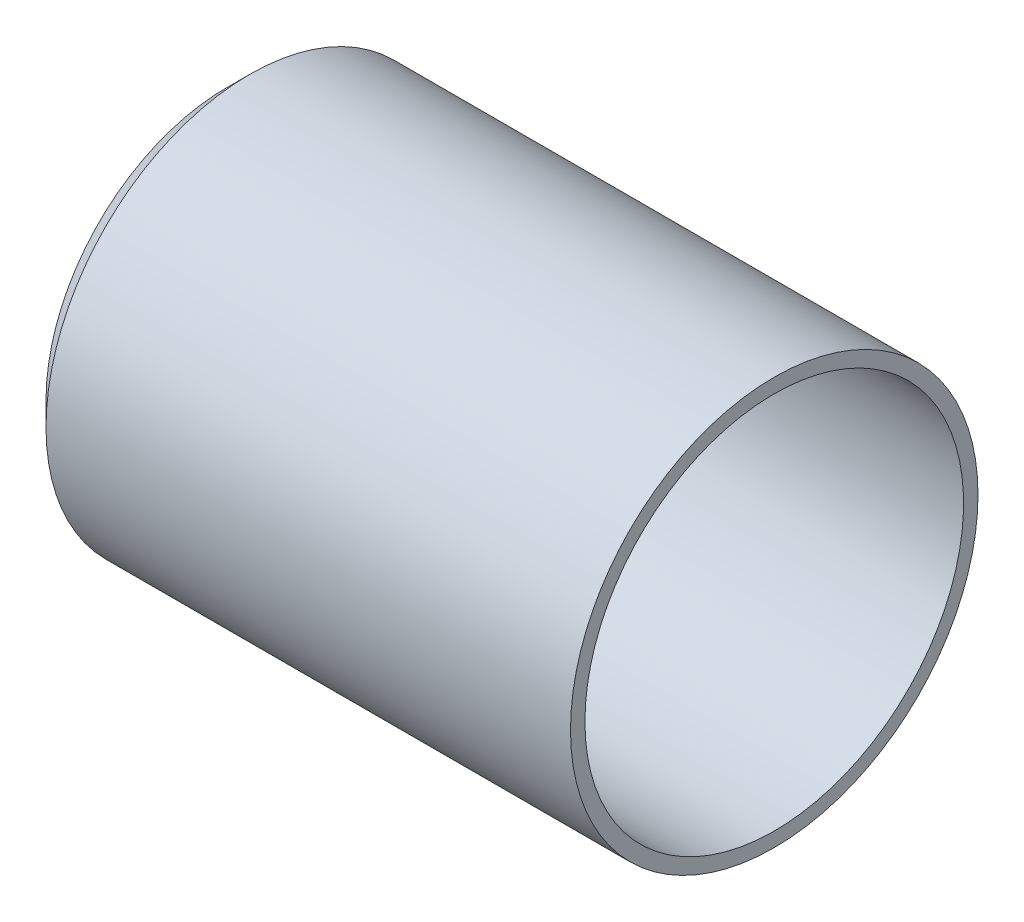
from build123d import *


with BuildPart() as part:
    # Sketch1 → Revolve1 (revolve)
    with BuildSketch(Plane.XY):
        Polygon((0, 9.231030735), (0.538815367, 8.692215367), (1.524, 9.6774), (27.9908, 9.6774), (27.9908, 10.414), (1.182969265, 10.414), align=None)
    revolve(axis=Axis((27.9908, 0, 0), (-1, 0, 0)))


solid = part.part
